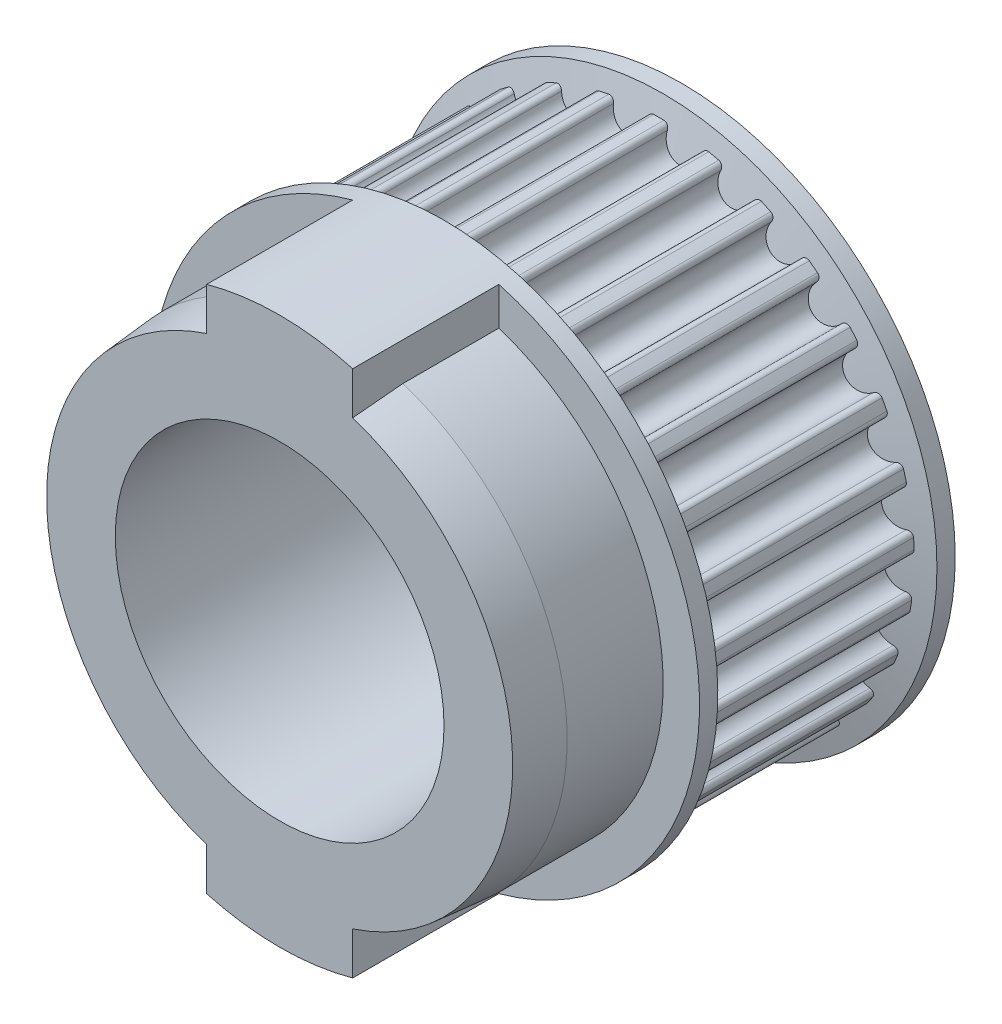
from build123d import *
from build123d.topology import SkipClean

# Parameters (mm, degrees)
SKETCH1_R               = 23.077466314
BOSS_EXTRUDE1_DEPTH     = 9.525
CUT_EXTRUDE1_DEPTH      = 34.998007706
CIRPATTERN1_COUNT       = 29
SKETCH4_R               = 23.794966314
SKETCH4_R_2             = 3.175
BOSS_EXTRUDE2_DEPTH     = 1.5875
SKETCH3_R               = 3.175
CUT_EXTRUDE2_DEPTH      = 40.475400569
CUT_EXTRUDE2_DEPTH_BACK = 40.475400569
SKETCH8_R               = 14.2875
SKETCH8_R_2             = 3.175
CUT_EXTRUDE3_DEPTH      = 41.328048283
SKETCH9_R               = 20.6375
SKETCH9_R_2             = 14.2875
BOSS_EXTRUDE3_DEPTH     = 12.7
CHAMFER1_SIZE           = 0.381
CHAMFER1_SIZE2          = 4.354849927
BOSS_EXTRUDE4_REACH     = 42.328


with BuildPart() as part:
    # Sketch1 → Boss-Extrude1 (new, symmetric)
    with BuildSketch(Plane.XY):
        with Locations(Location((0, 0, 0), (0, 0, 180))):
            Circle(SKETCH1_R)
    extrude(amount=BOSS_EXTRUDE1_DEPTH, both=True)

    # Sketch2 → Cut-Extrude1 (cut, symmetric)
    with BuildSketch(Plane.XY):
        with BuildLine():
            Line((0, 22.207466314), (0, 23.077466314))
            ThreePointArc((0, 23.077466314), (2.495113006, 22.942185218), (4.960973093, 22.537927976))
            Line((4.960973093, 22.537927976), (4.77394881, 21.688268093))
            ThreePointArc((4.77394881, 21.688268093), (4.555865829, 21.735124721), (4.337323211, 21.779788508))
            ThreePointArc((4.337323211, 21.779788508), (3.994020188, 21.701075564), (3.824699593, 21.39223381))
            ThreePointArc((3.824699593, 21.39223381), (2.178324282, 20.029361004), (0.863417677, 21.714292626))
            ThreePointArc((0.863417677, 21.714292626), (0.764447552, 22.052312755), (0.446091719, 22.202985436))
            ThreePointArc((0.446091719, 22.202985436), (0.223057111, 22.206346067), (0, 22.207466314))
        make_face()
    cut_extrude1 = extrude(amount=CUT_EXTRUDE1_DEPTH, both=True, mode=Mode.SUBTRACT)

    # CirPattern1: Cut-Extrude1 ×29 about axis
    cirpattern1_axis = Axis((0, 0, 0), (0, 0, 1))
    for i in range(1, CIRPATTERN1_COUNT):
        add(cut_extrude1.rotate(cirpattern1_axis, i * 360 / CIRPATTERN1_COUNT), mode=Mode.SUBTRACT)

    # Sketch4 → Boss-Extrude2 (add)
    with BuildSketch(Plane.XY.offset(9.525)):
        Circle(SKETCH4_R)
        Circle(SKETCH4_R_2, mode=Mode.SUBTRACT)
    boss_extrude2 = extrude(amount=BOSS_EXTRUDE2_DEPTH)

    # Sketch3 → Cut-Extrude2 (cut, two sides)
    with BuildSketch(Plane.XY.offset(11.1125)) as cut_extrude2_sk:
        Circle(SKETCH3_R)
    extrude(amount=CUT_EXTRUDE2_DEPTH, mode=Mode.SUBTRACT)
    extrude(cut_extrude2_sk.sketch, amount=-CUT_EXTRUDE2_DEPTH_BACK, mode=Mode.SUBTRACT)

    # Sketch6 → Revolve1 (revolve)
    with BuildSketch(Plane(origin=(0, 0, 0), x_dir=(1, 0, 0), z_dir=(0, 1, 0)), mode=Mode.PRIVATE) as revolve1_sk:
        Polygon((23.794966314, -9.525), (18.542, -8.255), (18.542, -9.525), align=None)
    revolve1 = revolve(revolve1_sk.sketch.rotate(Axis((0, 0, -9.525), (0, 0, 1)), 0.826416153), axis=Axis((0, 0, -9.525), (0, 0, 1)))

    # Mirror1: Boss-Extrude2, Revolve1 across plane
    add(boss_extrude2.mirror(Plane.XY))
    add(revolve1.mirror(Plane.XY))

    # Sketch8 → Cut-Extrude3 (cut, through all)
    with BuildSketch(Plane(origin=(0, 0, -11.1125), x_dir=(-1, 0, 0), z_dir=(0, 0, -1))):
        Circle(SKETCH8_R)
        Circle(SKETCH8_R_2, mode=Mode.SUBTRACT)
    extrude(amount=-CUT_EXTRUDE3_DEPTH, mode=Mode.SUBTRACT)

    # Sketch9 → Boss-Extrude3 (add)
    with BuildSketch(Plane.XY.offset(11.1125)):
        Circle(SKETCH9_R)
        with Locations(Location((0, 0, 0), (0, 0, 180))):
            Circle(SKETCH9_R_2, mode=Mode.SUBTRACT)
    extrude(amount=BOSS_EXTRUDE3_DEPTH)

    # Chamfer1
    chamfer1_edges = [part.edges().sort_by_distance(p)[0] for p in [
        (-20.6375, 0, 23.8125),
    ]]
    chamfer1_side = [part.faces().sort_by_distance(p)[0] for p in [
        (-20.053783352, 0, 23.8125),
    ]]
    chamfer(chamfer1_edges, length=CHAMFER1_SIZE, length2=CHAMFER1_SIZE2, reference=chamfer1_side[0])

    # Boss-Extrude4: up to this face of the body (flat: up to its plane)
    boss_extrude4_end = Plane(part.part.faces().sort_by_distance((-19.683559659, 0, 23.8125))[0])
    # Sketch10 → Boss-Extrude4 (add, up to the picked face)
    with BuildSketch(Plane.XY.offset(11.1125), mode=Mode.PRIVATE) as boss_extrude4_sk1:
        with BuildLine():
            Line((-6.35, 22.932028299), (-6.35, 19.235469639))
            ThreePointArc((-6.35, 19.235469639), (0, 20.2565), (6.35, 19.235469639))
            Line((6.35, 19.235469639), (6.35, 22.932028299))
            ThreePointArc((6.35, 22.932028299), (0, 23.794966314), (-6.35, 22.932028299))
        make_face()
    boss_extrude4_tool1 = split(extrude(boss_extrude4_sk1.sketch, amount=BOSS_EXTRUDE4_REACH, mode=Mode.PRIVATE), bisect_by=boss_extrude4_end, keep=Keep.BOTH, mode=Mode.PRIVATE)
    boss_extrude4 = boss_extrude4_tool1.solids().sort_by(Axis((0, 21.710912, 11.1125), (0, 0, 1)))[0]
    add(boss_extrude4)

    # Mirror2: Boss-Extrude4 across plane
    with SkipClean():  # the faces are left unmerged after this step: merging them gives an invalid solid
        add(boss_extrude4.mirror(Plane.ZX))


solid = part.part
